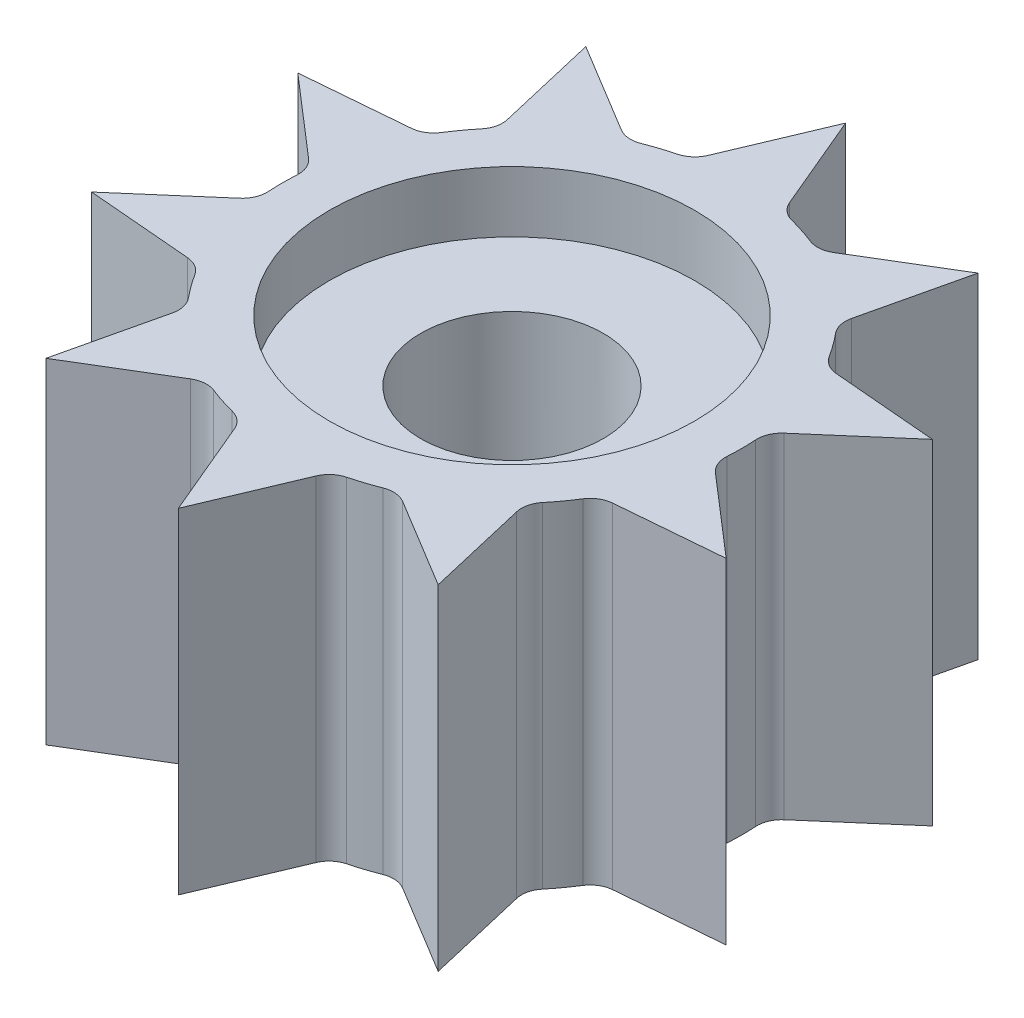
from build123d import *

# Parameters (mm, degrees)
BOSS_EXTRUDE1_DEPTH = 5.5
SKETCH2_R           = 1.5
CUT_EXTRUDE2_DEPTH  = 10.351104318
SKETCH2_4_R         = 3
SKETCH2_4_R_2       = 1.5
CUT_EXTRUDE3_DEPTH  = 1
CUT_EXTRUDE4_START  = -1
SKETCH4_R           = 3
CUT_EXTRUDE4_DEPTH  = 1


with BuildPart() as part:
    # Sketch1 → Boss-Extrude1 (new body)
    with BuildSketch(Plane(origin=(0, 0, 0), x_dir=(1, 0, 0), z_dir=(0, 1, 0))):
        with BuildLine():
            Line((0, 5.48), (-0.670562296, 3.888305602))
            ThreePointArc((-0.670562296, 3.888305602), (-0.777902483, 3.74073052), (-0.939622693, 3.656191214))
            ThreePointArc((-0.939622693, 3.656191214), (-1.166539154, 3.590238349), (-1.388884548, 3.510217189))
            ThreePointArc((-1.388884548, 3.510217189), (-1.569409904, 3.483554169), (-1.742992396, 3.53985194))
            Line((-1.742992396, 3.53985194), (-3.221063183, 4.433413129))
            Line((-3.221063183, 4.433413129), (-2.827984983, 2.751558684))
            ThreePointArc((-2.827984983, 2.751558684), (-2.828082561, 2.569074955), (-2.909226002, 2.405624465))
            ThreePointArc((-2.909226002, 2.405624465), (-3.054039154, 2.218889327), (-3.186885098, 2.023459505))
            ThreePointArc((-3.186885098, 2.023459505), (-3.31726105, 1.895778528), (-3.490783235, 1.839295151))
            Line((-3.490783235, 1.839295151), (-5.211789709, 1.693413129))
            Line((-5.211789709, 1.693413129), (-3.905213526, 0.56380987))
            ThreePointArc((-3.905213526, 0.56380987), (-3.798031224, 0.416120077), (-3.76760386, 0.236190934))
            ThreePointArc((-3.76760386, 0.236190934), (-3.775, 0), (-3.76760386, -0.236190934))
            ThreePointArc((-3.76760386, -0.236190934), (-3.798031224, -0.416120077), (-3.905213526, -0.56380987))
            Line((-3.905213526, -0.56380987), (-5.211789709, -1.693413129))
            Line((-5.211789709, -1.693413129), (-3.490783235, -1.839295151))
            ThreePointArc((-3.490783235, -1.839295151), (-3.31726105, -1.895778528), (-3.186885098, -2.023459505))
            ThreePointArc((-3.186885098, -2.023459505), (-3.054039154, -2.218889327), (-2.909226002, -2.405624465))
            ThreePointArc((-2.909226002, -2.405624465), (-2.828082561, -2.569074955), (-2.827984983, -2.751558684))
            Line((-2.827984983, -2.751558684), (-3.221063183, -4.433413129))
            Line((-3.221063183, -4.433413129), (-1.742992396, -3.53985194))
            ThreePointArc((-1.742992396, -3.53985194), (-1.569409904, -3.483554169), (-1.388884548, -3.510217189))
            ThreePointArc((-1.388884548, -3.510217189), (-1.166539154, -3.590238349), (-0.939622693, -3.656191214))
            ThreePointArc((-0.939622693, -3.656191214), (-0.777902483, -3.74073052), (-0.670562296, -3.888305602))
            Line((-0.670562296, -3.888305602), (0, -5.48))
            Line((0, -5.48), (0.670562296, -3.888305602))
            ThreePointArc((0.670562296, -3.888305602), (0.777902483, -3.74073052), (0.939622693, -3.656191214))
            ThreePointArc((0.939622693, -3.656191214), (1.166539154, -3.590238349), (1.388884548, -3.510217189))
            ThreePointArc((1.388884548, -3.510217189), (1.569409904, -3.483554169), (1.742992396, -3.53985194))
            Line((1.742992396, -3.53985194), (3.221063183, -4.433413129))
            Line((3.221063183, -4.433413129), (2.827984983, -2.751558684))
            ThreePointArc((2.827984983, -2.751558684), (2.828082561, -2.569074955), (2.909226002, -2.405624465))
            ThreePointArc((2.909226002, -2.405624465), (3.054039154, -2.218889327), (3.186885098, -2.023459505))
            ThreePointArc((3.186885098, -2.023459505), (3.31726105, -1.895778528), (3.490783235, -1.839295151))
            Line((3.490783235, -1.839295151), (5.211789709, -1.693413129))
            Line((5.211789709, -1.693413129), (3.905213526, -0.56380987))
            ThreePointArc((3.905213526, -0.56380987), (3.798031224, -0.416120077), (3.76760386, -0.236190934))
            ThreePointArc((3.76760386, -0.236190934), (3.775, 0), (3.76760386, 0.236190934))
            ThreePointArc((3.76760386, 0.236190934), (3.798031224, 0.416120077), (3.905213526, 0.56380987))
            Line((3.905213526, 0.56380987), (5.211789709, 1.693413129))
            Line((5.211789709, 1.693413129), (3.490783235, 1.839295151))
            ThreePointArc((3.490783235, 1.839295151), (3.31726105, 1.895778528), (3.186885098, 2.023459505))
            ThreePointArc((3.186885098, 2.023459505), (3.054039154, 2.218889327), (2.909226002, 2.405624465))
            ThreePointArc((2.909226002, 2.405624465), (2.828082561, 2.569074955), (2.827984983, 2.751558684))
            Line((2.827984983, 2.751558684), (3.221063183, 4.433413129))
            Line((3.221063183, 4.433413129), (1.742992396, 3.53985194))
            ThreePointArc((1.742992396, 3.53985194), (1.569409904, 3.483554169), (1.388884548, 3.510217189))
            ThreePointArc((1.388884548, 3.510217189), (1.166539154, 3.590238349), (0.939622693, 3.656191214))
            ThreePointArc((0.939622693, 3.656191214), (0.777902483, 3.74073052), (0.670562296, 3.888305602))
            Line((0.670562296, 3.888305602), (0, 5.48))
        make_face()
    extrude(amount=BOSS_EXTRUDE1_DEPTH)

    # Sketch2 → Cut-Extrude2 (cut, through all)
    with BuildSketch(Plane(origin=(0, 5.5, 0), x_dir=(1, 0, 0), z_dir=(0, 1, 0))):
        Circle(SKETCH2_R)
    extrude(amount=-CUT_EXTRUDE2_DEPTH, mode=Mode.SUBTRACT)

    # Sketch2_4 → Cut-Extrude3 (cut)
    with BuildSketch(Plane(origin=(0, 5.5, 0), x_dir=(1, 0, 0), z_dir=(0, 1, 0))):
        Circle(SKETCH2_4_R)
        Circle(SKETCH2_4_R_2, mode=Mode.SUBTRACT)
    extrude(amount=-CUT_EXTRUDE3_DEPTH, mode=Mode.SUBTRACT)

    # Sketch4 → Cut-Extrude4 (cut)
    with BuildSketch(Plane.XZ.offset(CUT_EXTRUDE4_START)):
        Circle(SKETCH4_R)
    extrude(amount=CUT_EXTRUDE4_DEPTH, mode=Mode.SUBTRACT)


solid = part.part
